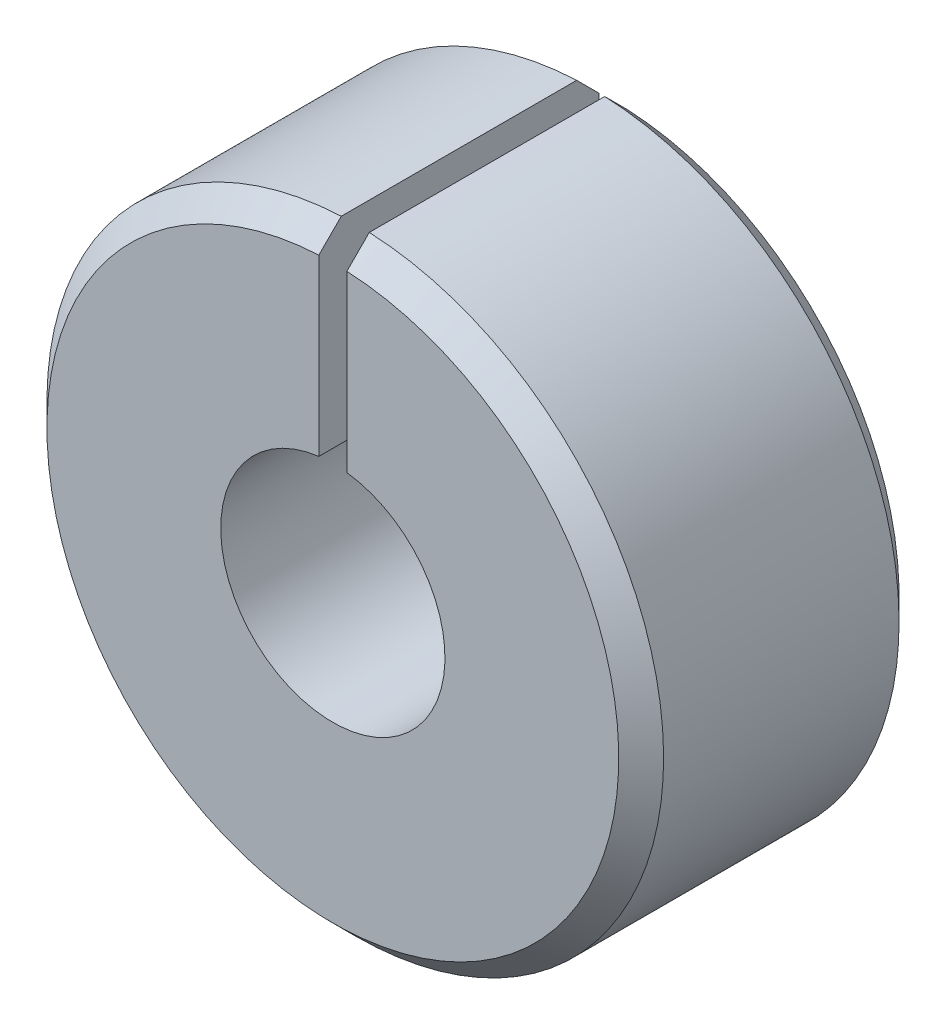
from build123d import *

# Parameters (mm, degrees)
EXTRUSION_DEPTH = 3.96875
CHAMFER1_SIZE   = 0.635


with BuildPart() as part:
    # profile → extrusion (new body, symmetric)
    with BuildSketch(Plane.XY):
        with BuildLine():
            Line((-0.396875, 3.150097655), (-0.396875, 8.72222545))
            ThreePointArc((-0.396875, 8.72222545), (0, -8.73125), (0.396875, 8.72222545))
            Line((0.396875, 8.72222545), (0.396875, 3.150097655))
            ThreePointArc((0.396875, 3.150097655), (0, -3.175), (-0.396875, 3.150097655))
        make_face()
    extrude(amount=EXTRUSION_DEPTH, both=True)

    # Chamfer1
    chamfer1_edges = [part.edges().sort_by_distance(p)[0] for p in [
        (0, -8.73125, 3.96875),
        (0, -8.73125, -3.96875),
    ]]
    chamfer(chamfer1_edges, length=CHAMFER1_SIZE)


solid = part.part
